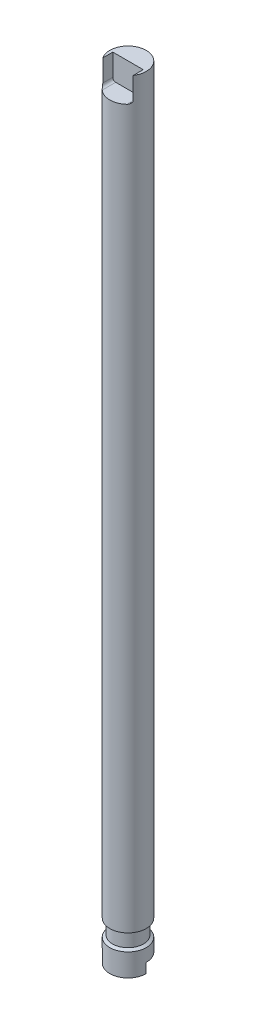
from build123d import *

# Parameters (mm, degrees)
SKETCH_2_R               = 2.8
EXTRUDE_1_DEPTH          = 120
SKETCH_3_W               = 5.6
SKETCH_3_H               = 1.5
CUT_EXTRUDE_2_DEPTH      = 121.065315558
CUT_EXTRUDE_6_DEPTH      = 121.065315558
CUT_EXTRUDE_6_DEPTH_BACK = 0.0001
SCALE_1_SCALE            = 10


with BuildPart() as part:
    # Эскиз2 → Вытянуть1 (new body)
    with BuildSketch(Plane(origin=(0, 0, 0), x_dir=(1, 0, 0), z_dir=(0, 1, 0))):
        Circle(SKETCH_2_R)
    extrude(amount=EXTRUDE_1_DEPTH)

    # Эскиз3 → Вытянуть2 (cut, through all)
    with BuildSketch(Plane.XY):
        with Locations((0, 0.75)):
            Rectangle(SKETCH_3_W, SKETCH_3_H)
    extrude(amount=-CUT_EXTRUDE_2_DEPTH, mode=Mode.SUBTRACT)

    # Эскиз5 → Вырез-Повернуть1 (revolve, cut)
    with BuildSketch(Plane.XY):
        Polygon((-2.375975952, 5.731640408), (-2.8, 5.99660004), (-2.8, 3.466680776), (-2.375975952, 3.731640408), align=None)
    revolve(axis=Axis((0, 0, 0), (0, 1, 0)), mode=Mode.SUBTRACT)

    # Эскиз6 → Вытянуть6 (cut, two sides: drawn at the far end of the back side and taken through both)
    with BuildSketch(Plane.XY.offset(-CUT_EXTRUDE_6_DEPTH_BACK)):
        with BuildLine():
            Line((-2.337778294, 120.351251099), (-2.337778294, 116.645068544))
            ThreePointArc((-2.337778294, 116.645068544), (-2.207612569, 116.330820685), (-1.89336471, 116.20065496))
            Line((-1.89336471, 116.20065496), (1.89336471, 116.20065496))
            ThreePointArc((1.89336471, 116.20065496), (2.207612569, 116.330820685), (2.337778294, 116.645068544))
            Line((2.337778294, 116.645068544), (2.337778294, 120.351251099))
            Line((2.337778294, 120.351251099), (-2.337778294, 120.351251099))
        make_face()
    extrude(amount=CUT_EXTRUDE_6_DEPTH + CUT_EXTRUDE_6_DEPTH_BACK, mode=Mode.SUBTRACT)


with BuildPart() as part_1:
    # Масштаб1: scaled about (-2e-09, 59.813507697, -0.010902497)
    add(part.part.scale(SCALE_1_SCALE).moved(Location((1.8e-08, -538.321569273, 0.098122473))))


solid = part_1.part
